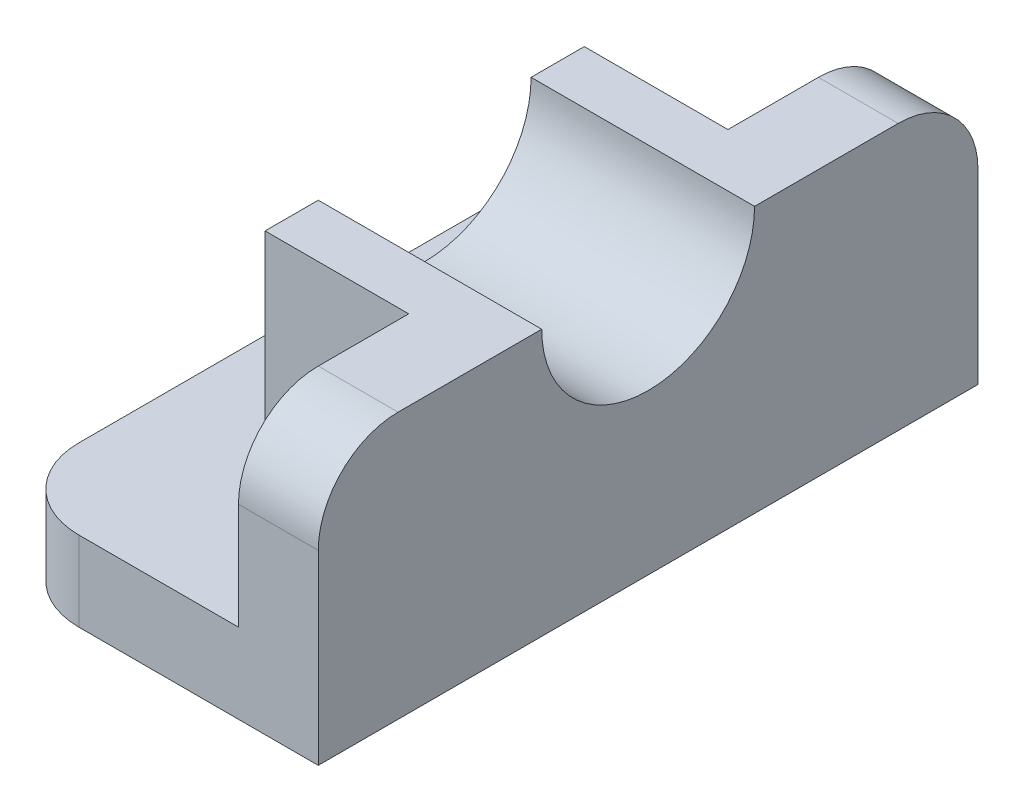
from build123d import *

# Parameters (mm, degrees)
BOSS_EXTRUDE2_DEPTH = 124
FILLET1_R           = 15
FILLET2_R           = 15
SKETCH2_W           = 60
SKETCH2_H           = 35
BOSS_EXTRUDE3_DEPTH = 27
SKETCH5_R           = 20
CUT_EXTRUDE8_DEPTH  = 50


with BuildPart() as part:
    # Sketch1 → Boss-Extrude2 (new body)
    with BuildSketch(Plane.XY):
        Polygon((0, 0), (60, 0), (60, 50), (45, 50), (45, 15), (0, 15), align=None)
    extrude(amount=BOSS_EXTRUDE2_DEPTH)

    # Fillet1
    fillet1_edges = [part.edges().sort_by_distance(p)[0] for p in [
        (52.5, 50, 124),
        (0, 7.5, 124),
        (52.5, 50, 0),
    ]]
    fillet(fillet1_edges, radius=FILLET1_R)

    # Fillet2
    fillet2_edges = [part.edges().sort_by_distance(p)[0] for p in [
        (0, 7.5, 0),
    ]]
    fillet(fillet2_edges, radius=FILLET2_R)

    # Sketch2 → Boss-Extrude3 (add)
    with BuildSketch(Plane.ZY.offset(-45)):
        with Locations((62, 32.5)):
            Rectangle(SKETCH2_W, SKETCH2_H)
    extrude(amount=BOSS_EXTRUDE3_DEPTH)

    # Sketch5 → Cut-Extrude8 (cut)
    with BuildSketch(Plane.ZY.offset(-18)):
        with Locations((62, 50)):
            Circle(SKETCH5_R)
    extrude(amount=-CUT_EXTRUDE8_DEPTH, mode=Mode.SUBTRACT)


solid = part.part
